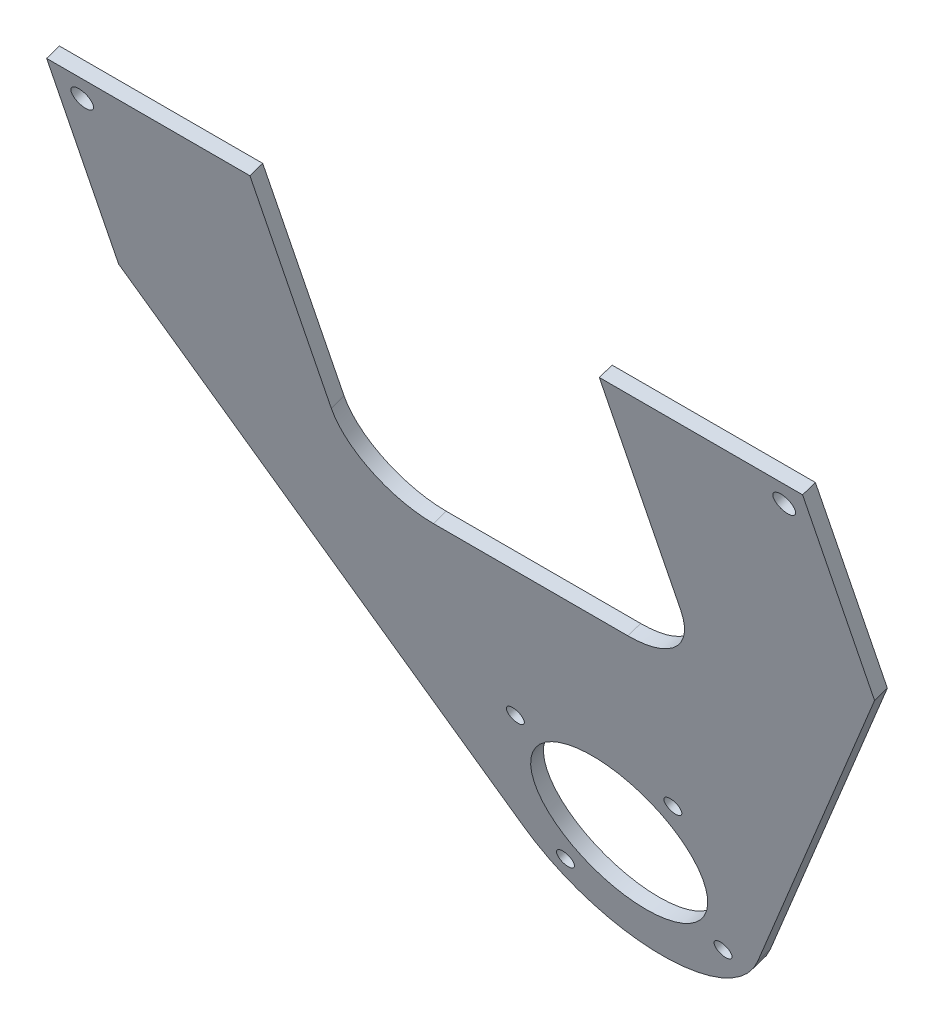
from build123d import *

# Parameters (mm, degrees)
SKETCH1_R               = 19.84375
BOSS_EXTRUDE1_DEPTH     = 3.175
F_1_4_20_TAPPED_HOLE1_D = 5.1054
F_10_32_TAPPED_HOLE1_D  = 4.0386
CUT_EXTRUDE1_DEPTH      = 57.13926808


with BuildPart() as part:
    # Sketch1 → Boss-Extrude1 (new body)
    with BuildSketch(Plane(origin=(0, -335.48880086, 998.033966912), x_dir=(1, 0, 0), z_dir=(0, -0.318629355, 0.947879388))):
        with BuildLine():
            Line((-88.9, 1035.868385599), (-88.9, 982.73222125))
            Line((-88.9, 982.73222125), (-27.49630657, 876.377904457))
            ThreePointArc((-27.49630657, 876.377904457), (0, 860.502904457), (27.49630657, 876.377904457))
            Line((27.49630657, 876.377904457), (88.9, 982.73222125))
            Line((88.9, 982.73222125), (88.9, 1035.868385599))
            Line((88.9, 1035.868385599), (-88.9, 1035.868385599))
        make_face()
        with Locations((0, 892.252904457)):
            Circle(SKETCH1_R, mode=Mode.SUBTRACT)
    extrude(amount=BOSS_EXTRUDE1_DEPTH)

    # 1/4-20 Tapped Hole1 (through all)
    with Locations(Plane(origin=(0, -336.500449063, 1001.043483969), x_dir=(1, 0, 0), z_dir=(0, -0.318629355, 0.947879388))):
        with Locations((82.55, 1029.518385599), (-82.55, 1029.518385599)):
            Hole(F_1_4_20_TAPPED_HOLE1_D / 2)

    # #10-32 Tapped Hole1 (through all)
    with Locations(Plane(origin=(0, -336.500449063, 1001.043483969), x_dir=(1, 0, 0), z_dir=(0, -0.318629355, 0.947879388))):
        with Locations((18.52177825, 873.731126207), (-18.52177825, 873.731126207), (-18.52177825, 910.774682707), (18.52177825, 910.774682707)):
            Hole(F_10_32_TAPPED_HOLE1_D / 2)

    # Sketch6 → Cut-Extrude1 (cut, through all)
    with BuildSketch(Plane(origin=(0, -335.48880086, 998.033966912), x_dir=(-1, 0, 0), z_dir=(0, 0.318629355, -0.947879388))):
        with BuildLine():
            Line((-41.090457195, 975.803721018), (-41.090457195, 1046.47326385))
            Line((-41.090457195, 1046.47326385), (41.0904572, 1046.47326385))
            Line((41.0904572, 1046.47326385), (41.090457191, 975.803721018))
            ThreePointArc((41.090457191, 975.803721018), (35.75087991, 962.91284113), (22.860000022, 957.57326385))
            Line((22.860000022, 957.57326385), (-22.860000028, 957.57326385))
            ThreePointArc((-22.860000028, 957.57326385), (-35.750879915, 962.91284113), (-41.090457195, 975.803721018))
        make_face()
    extrude(amount=-CUT_EXTRUDE1_DEPTH, mode=Mode.SUBTRACT)


solid = part.part
